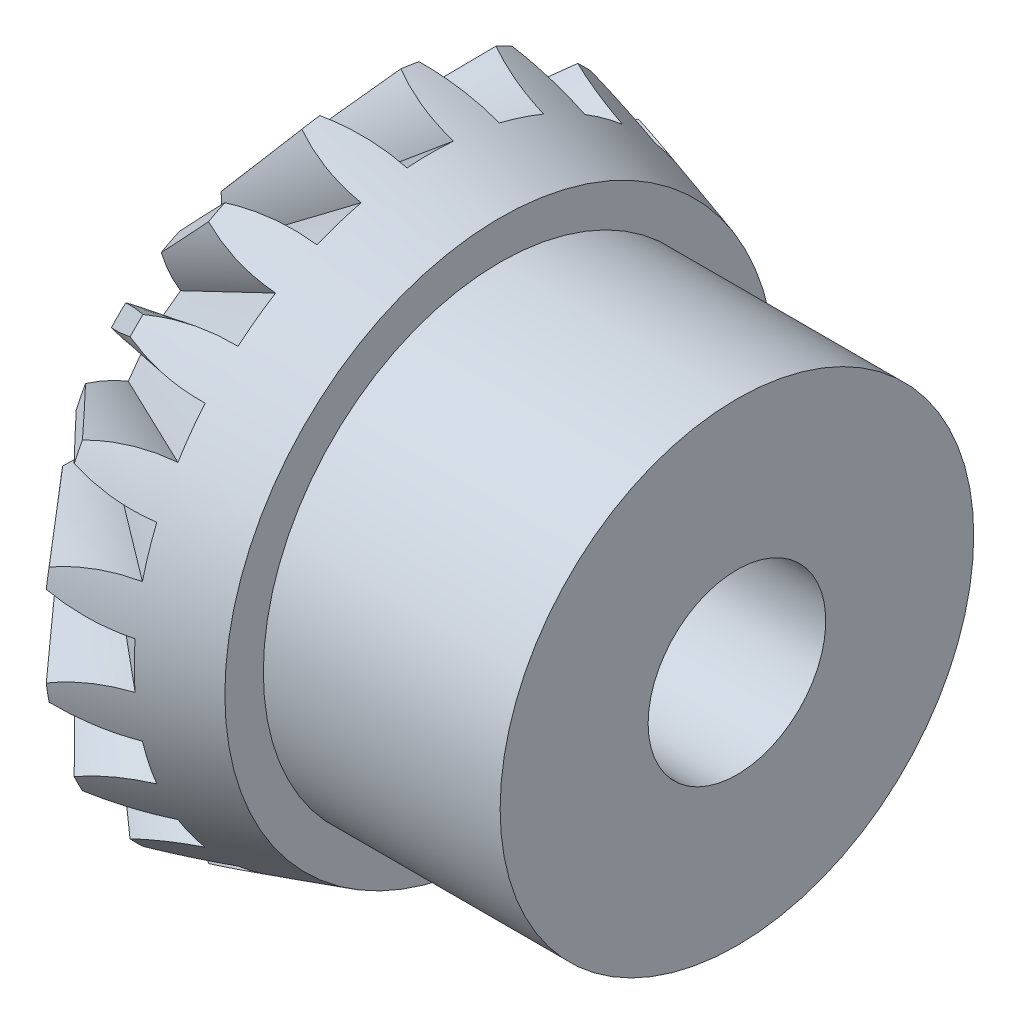
from build123d import *

# Parameters (mm, degrees)
CIRPATTERN1_COUNT = 20


with BuildPart() as part:
    # Sketch1 → Revolve1 (revolve)
    with BuildSketch(Plane.XY):
        Polygon((0, 1.5), (8, 1.5), (8, 4), (4, 4), (4, 4.65), (1.639708456, 5.35), (0, 3.462844421), align=None)
    revolve(axis=Axis((0, 0, 0), (1, 0, 0)))

    # Sketch6 for Cut-Loft1 → Cut-Loft1 section 0
    with BuildSketch(Plane(origin=(2.819854228, 0, 0), x_dir=(0, 0, -1), z_dir=(1, 0, 0))):
        with BuildLine():
            Line((-2.607480562, 8.025), (2.607480562, 8.025))
            # circular arc as an exact rational Bezier (weights 1, cos(half-angle), 1)
            Bezier((2.607480562, 8.025), (0.565515721, 7.185558531), (0.392295479, 4.984586669), weights=[1, 0.851943225, 1])
            Bezier((0.392295479, 4.984586669), (0, 5.015460992), (-0.392295479, 4.984586669), weights=[1, 0.996917334, 1])
            Bezier((-0.392295479, 4.984586669), (-0.565515721, 7.185558531), (-2.607480562, 8.025), weights=[1, 0.851943225, 1])
        make_face()
    # Sketch5 for Cut-Loft1 → Cut-Loft1 section 1
    with BuildSketch(Plane.ZY):
        with BuildLine():
            Line((-0.209878081, 2.666753868), (0.209878081, 2.666753868))
            Bezier((0.209878081, 2.666753868), (0.33323155, 4.2341083), (1.65324092, 5.088152362), weights=[1, 0.896497279, 1])
            Bezier((1.65324092, 5.088152362), (0, 5.6253229), (-1.65324092, 5.088152362), weights=[1, 0.951056516, 1])
            Bezier((-1.65324092, 5.088152362), (-0.33323155, 4.2341083), (-0.209878081, 2.666753868), weights=[1, 0.896497279, 1])
        make_face()
    cut_loft1 = loft(mode=Mode.SUBTRACT)

    # CirPattern1: Cut-Loft1 ×20 about axis
    cirpattern1_axis = Axis((0, 0, 0), (-1, 0, 0))
    for i in range(1, CIRPATTERN1_COUNT):
        add(cut_loft1.rotate(cirpattern1_axis, i * 360 / CIRPATTERN1_COUNT), mode=Mode.SUBTRACT)


solid = part.part
